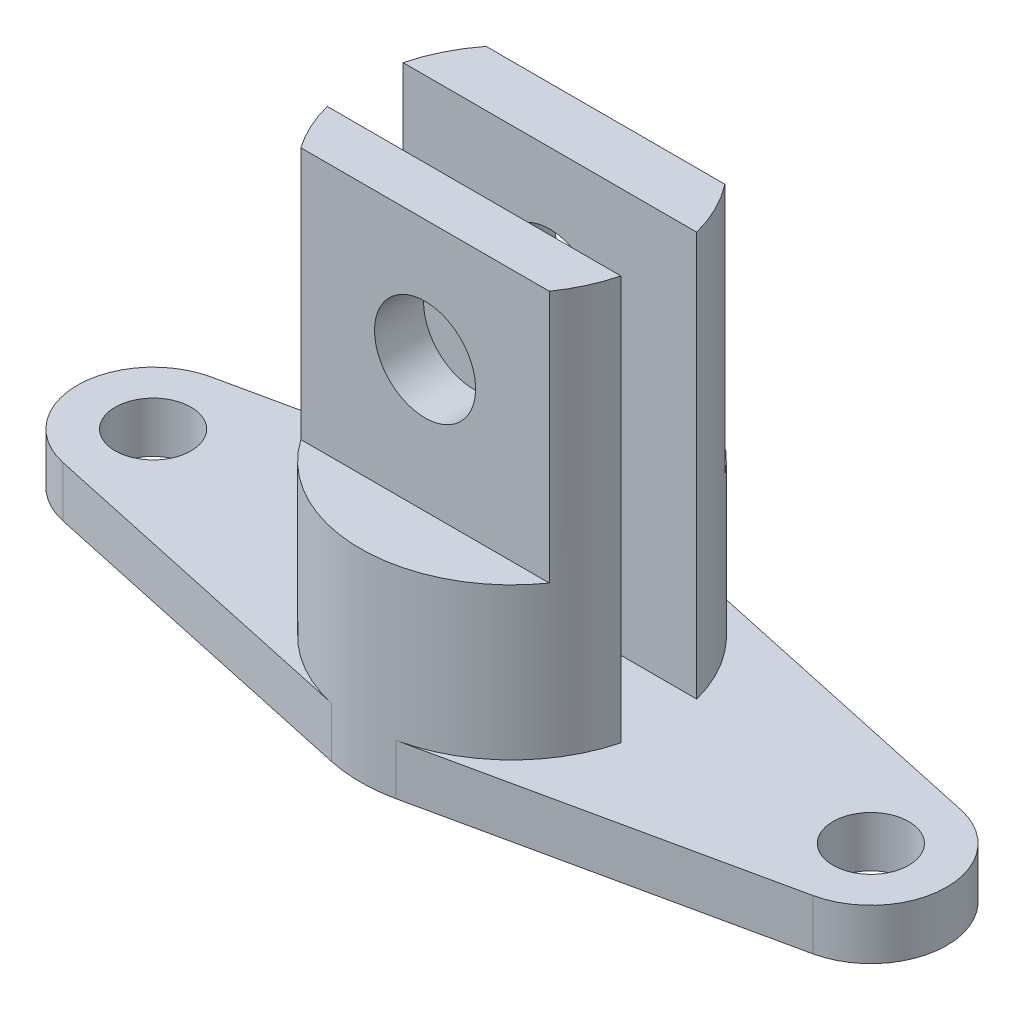
from build123d import *

# Parameters (mm, degrees)
CROQUIS1_R              = 7.5
SALIENTE_EXTRUIR1_DEPTH = 10
SALIENTE_EXTRUIR2_DEPTH = 80
CORTAR_EXTRUIR1_DEPTH   = 50
CROQUIS5_R              = 10
CORTAR_EXTRUIR2_DEPTH   = 50
CORTAR_EXTRUIR3_DEPTH   = 50


with BuildPart() as part:
    # Croquis1 → Saliente-Extruir1 (new body)
    with BuildSketch(Plane(origin=(0, 0, 0), x_dir=(1, 0, 0), z_dir=(0, 1, 0))):
        with BuildLine():
            Line((-6.338028169, 29.322847729), (-74.169014085, 14.661423864))
            ThreePointArc((-74.169014085, 14.661423864), (-86, 0), (-74.169014085, -14.661423864))
            Line((-74.169014085, -14.661423864), (-6.338028169, -29.322847729))
            ThreePointArc((-6.338028169, -29.322847729), (0, -30), (6.338028169, -29.322847729))
            Line((6.338028169, -29.322847729), (74.169014085, -14.661423864))
            ThreePointArc((74.169014085, -14.661423864), (86, 0), (74.169014085, 14.661423864))
            Line((74.169014085, 14.661423864), (6.338028169, 29.322847729))
            ThreePointArc((6.338028169, 29.322847729), (0, 30), (-6.338028169, 29.322847729))
        make_face()
        with Locations((-71, 0)):
            Circle(CROQUIS1_R, mode=Mode.SUBTRACT)
        with Locations((71, 0)):
            Circle(CROQUIS1_R, mode=Mode.SUBTRACT)
    extrude(amount=SALIENTE_EXTRUIR1_DEPTH)

    # Croquis2 → Saliente-Extruir2 (add)
    with BuildSketch(Plane(origin=(0, 10, 0), x_dir=(1, 0, 0), z_dir=(0, 1, 0))):
        with BuildLine():
            Line((29.047375097, -7.5), (-29.047375097, -7.5))
            ThreePointArc((-29.047375097, -7.5), (-20.786795371, -21.631207506), (-6.338028169, -29.322847729))
            ThreePointArc((-6.338028169, -29.322847729), (0, -30), (6.338028169, -29.322847729))
            ThreePointArc((6.338028169, -29.322847729), (20.786795371, -21.631207506), (29.047375097, -7.5))
        make_face()
        with BuildLine():
            ThreePointArc((-6.338028169, 29.322847729), (-20.786795371, 21.631207506), (-29.047375097, 7.5))
            Line((-29.047375097, 7.5), (29.047375097, 7.5))
            ThreePointArc((29.047375097, 7.5), (20.786795371, 21.631207506), (6.338028169, 29.322847729))
            ThreePointArc((6.338028169, 29.322847729), (0, 30), (-6.338028169, 29.322847729))
        make_face()
    extrude(amount=SALIENTE_EXTRUIR2_DEPTH)

    # Croquis4 → Cortar-Extruir1 (cut)
    with BuildSketch(Plane(origin=(0, 90, 0), x_dir=(1, 0, 0), z_dir=(0, 1, 0))):
        with BuildLine():
            Line((-23.616731357, 18.5), (23.616731357, 18.5))
            ThreePointArc((23.616731357, 18.5), (0, 30), (-23.616731357, 18.5))
        make_face()
    extrude(amount=-CORTAR_EXTRUIR1_DEPTH, mode=Mode.SUBTRACT)

    # Croquis5 → Cortar-Extruir2 (cut)
    with BuildSketch(Plane(origin=(0, 0, -18.5), x_dir=(-1, 0, 0), z_dir=(0, 0, -1))):
        with Locations((0, 66)):
            Circle(CROQUIS5_R)
    extrude(amount=-CORTAR_EXTRUIR2_DEPTH, mode=Mode.SUBTRACT)

    # Croquis6 → Cortar-Extruir3 (cut)
    with BuildSketch(Plane(origin=(0, 90, 0), x_dir=(1, 0, 0), z_dir=(0, 1, 0))):
        with BuildLine():
            Line((-24.57931818, -17.200497604), (24.57931818, -17.200497604))
            ThreePointArc((24.57931818, -17.200497604), (0, -30), (-24.57931818, -17.200497604))
        make_face()
    extrude(amount=-CORTAR_EXTRUIR3_DEPTH, mode=Mode.SUBTRACT)


solid = part.part
